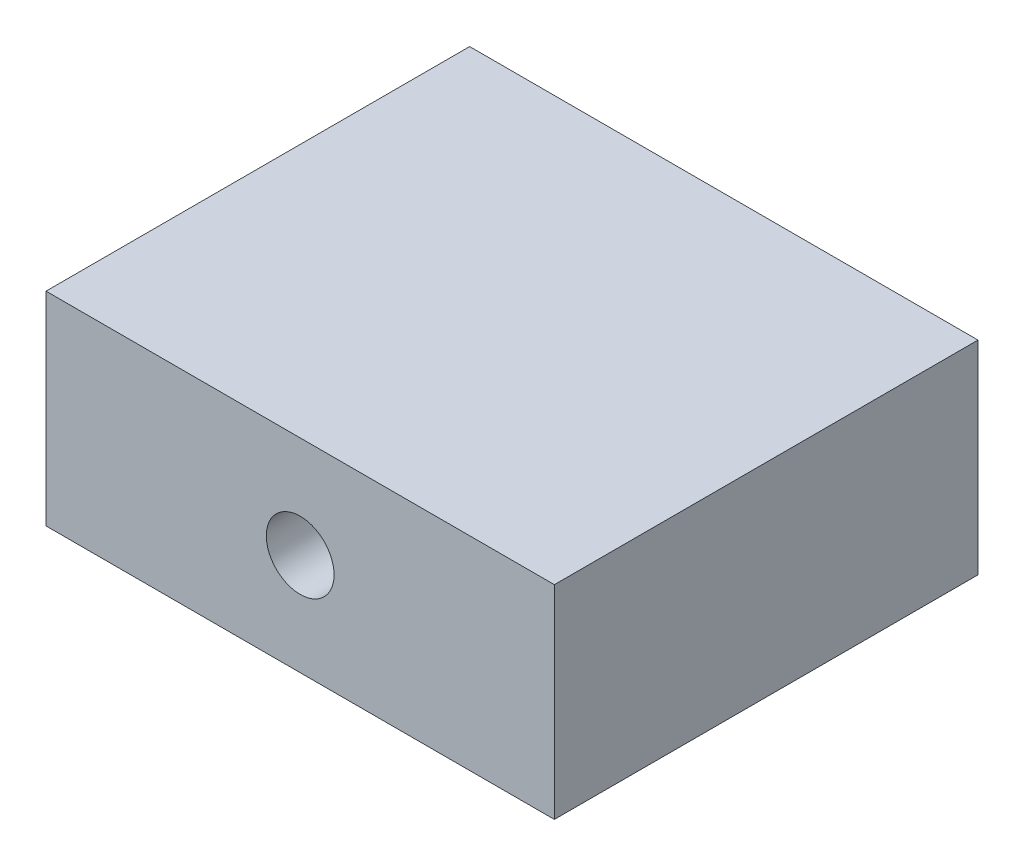
from build123d import *

# Parameters (mm, degrees)
SKETCH_1_W          = 30
SKETCH_1_H          = 25
EXTRUDE_1_DEPTH     = 12
CUT_EXTRUDE_1_DEPTH = 25


with BuildPart() as part:
    # 草图1 → 凸台-拉伸1 (new body)
    with BuildSketch(Plane(origin=(0, 0, 0), x_dir=(1, 0, 0), z_dir=(0, 1, 0))):
        with Locations((15, 12.5)):
            Rectangle(SKETCH_1_W, SKETCH_1_H)
    extrude(amount=EXTRUDE_1_DEPTH)

    # 草图2 → 切除-拉伸1 (cut)
    with BuildSketch(Plane.XY):
        with BuildLine():
            ThreePointArc((16.856953382, 6.742781353), (15, 8), (13.143046618, 6.742781353))
            Line((13.143046618, 6.742781353), (15, 6))
            Line((15, 6), (16.856953382, 6.742781353))
        make_face()
        with BuildLine():
            Line((15, 6), (13.143046618, 6.742781353))
            ThreePointArc((13.143046618, 6.742781353), (13, 6), (13.143046618, 5.257218647))
            Line((13.143046618, 5.257218647), (15, 6))
        make_face()
        with BuildLine():
            Line((16.856953382, 6.742781353), (15, 6))
            Line((15, 6), (16.856953382, 5.257218647))
            ThreePointArc((16.856953382, 5.257218647), (16.963912773, 5.621784958), (17, 6))
            ThreePointArc((17, 6), (16.963912773, 6.378215042), (16.856953382, 6.742781353))
        make_face()
        with BuildLine():
            Line((16.856953382, 5.257218647), (15, 6))
            Line((15, 6), (13.143046618, 5.257218647))
            ThreePointArc((13.143046618, 5.257218647), (15, 4), (16.856953382, 5.257218647))
        make_face()
    extrude(amount=-CUT_EXTRUDE_1_DEPTH, mode=Mode.SUBTRACT)


solid = part.part
